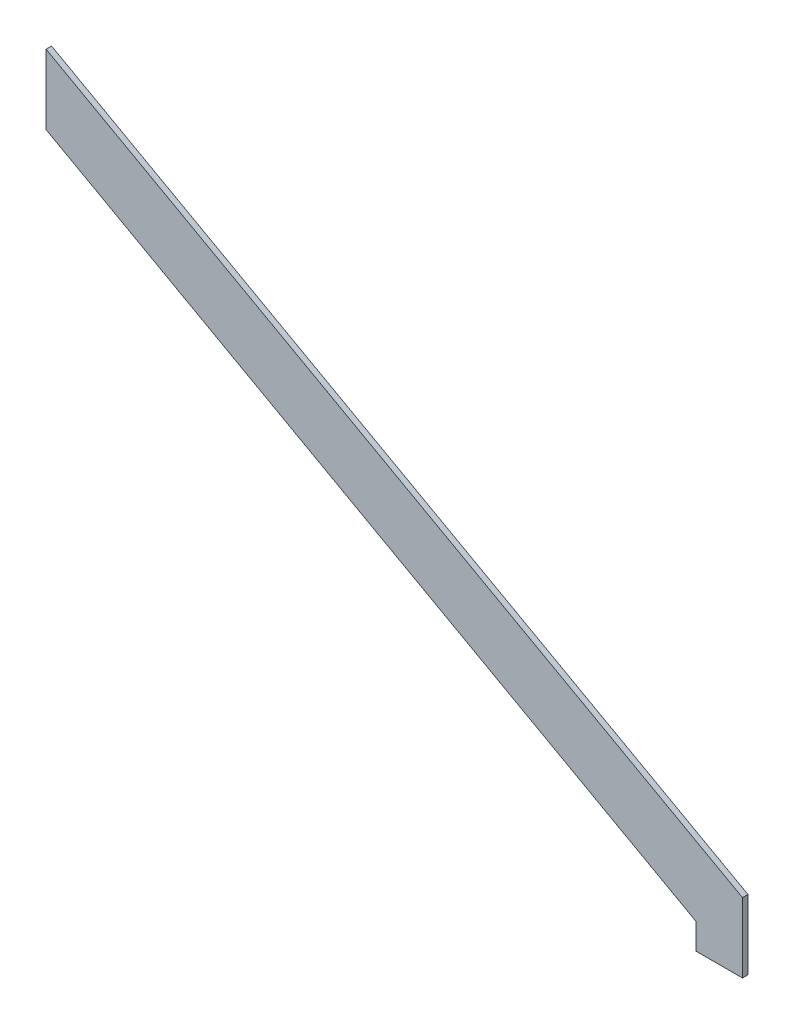
from build123d import *

# Parameters (mm, degrees)
BOSS_EXTRUDE1_DEPTH = 3
BOSS_EXTRUDE2_DEPTH = 3


with BuildPart() as part:
    # Sketch1 → Boss-Extrude1 (new body)
    with BuildSketch(Plane.XY):
        Polygon((-381, 211.461110197), (0, 0), (0, 38.1), (-381, 249.561110197), align=None)
    extrude(amount=BOSS_EXTRUDE1_DEPTH)

    # Sketch3 → Boss-Extrude2 (add)
    with BuildSketch(Plane.XY.offset(3)):
        Polygon((0, 0), (-25.4, 0), (-25.4, 14.097407346), align=None)
    extrude(amount=-BOSS_EXTRUDE2_DEPTH)


solid = part.part
